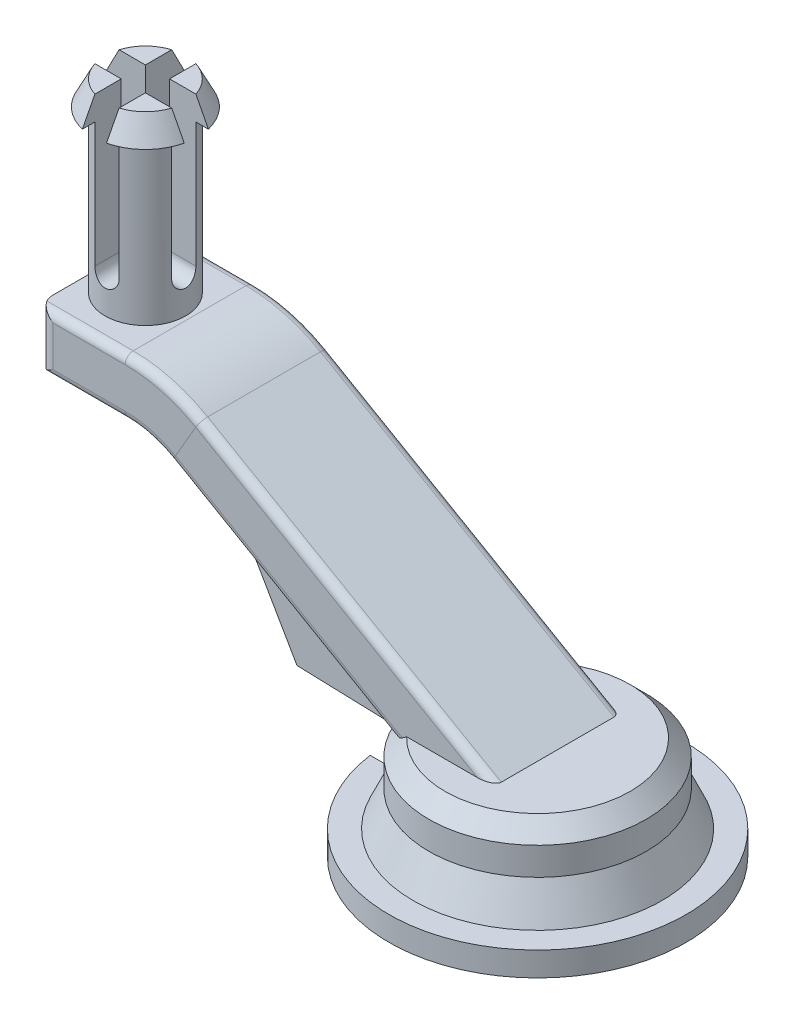
from build123d import *

# Parameters (mm, degrees)
CORTAR_EXTRUIR2_DEPTH         = 4.5
SALIENTE_EXTRUIR2_START       = -4.5
CROQUIS5_W                    = 16
CROQUIS5_H                    = 1.6
SALIENTE_EXTRUIR2_DEPTH       = 4.5
CROQUIS6_R                    = 2
SALIENTE_EXTRUIR3_DEPTH       = 4.4
SALIENTE_EXTRUIR10_DEPTH      = 4
SALIENTE_EXTRUIR10_DEPTH_BACK = 4
SALIENTE_EXTRUIR14_DEPTH      = 2
SALIENTE_EXTRUIR15_DEPTH      = 8
CORTAR_EXTRUIR3_DEPTH         = 2.5
CORTAR_EXTRUIR3_DEPTH_BACK    = 2.5
CROQUIS16_R                   = 2.5
CORTAR_EXTRUIR4_DEPTH         = 5
SALIENTE_EXTRUIR16_REACH      = 28.151
CROQUIS20_R                   = 5
SALIENTE_EXTRUIR17_DEPTH      = 20
CORTAR_EXTRUIR5_DEPTH         = 20
CORTAR_EXTRUIR6_DEPTH         = 20
CORTAR_EXTRUIR6_DEPTH_BACK    = 20
CORTAR_EXTRUIR7_DEPTH         = 16
CORTAR_EXTRUIR8_DEPTH         = 16
CROQUIS28_W                   = 13.74427346
CROQUIS28_H                   = 0.2
CORTAR_EXTRUIR9_DEPTH         = 1.6
SALIENTE_EXTRUIR18_DEPTH      = 2
SALIENTE_EXTRUIR19_DEPTH      = 2
CROQUIS31_R                   = 18.46058459
CORTAR_EXTRUIR10_DEPTH        = 10
CORTAR_EXTRUIR11_DEPTH        = 2
CORTAR_EXTRUIR11_DEPTH_BACK   = 1
CROQUIS33_R                   = 2.5
CORTAR_EXTRUIR12_DEPTH        = 6


with BuildPart() as part:
    # Croquis1 → Revoluci_n1 (revolve)
    with BuildSketch(Plane(origin=(53.410009494, 0, 0), x_dir=(0, 0, -1), z_dir=(1, 0, 0)), mode=Mode.PRIVATE) as revoluci_n1_sk:
        Polygon((0.52, 82.76), (10.040007849, 82.76), (11.02, 79.330027472), (11.02, 76.76), (14.02, 76.76), (14.02, 83.76), (12.02, 85.76), (0.52, 85.76), align=None)
    revolve(revoluci_n1_sk.sketch.rotate(Axis((53.410009494, 92.179923536, -0.52), (0, -1, 0)), 180), axis=Axis((53.410009494, 92.179923536, -0.52), (0, -1, 0)))  # turned: the seam where the file's is

    # Croquis4 → Cortar-Extruir2 (cut)
    with BuildSketch(Plane(origin=(0, 0, -2.77), x_dir=(-1, 0, 0), z_dir=(0, 0, -1))):
        Polygon((-49.430009494, 82.38), (-49.430009494, 81.16), (-58.115009494, 81.16), (-58.592032087, 81.16), (-58.592032087, 78.172909834), (-58.592032087, 74.185148135), (-34.769920464, 74.185148135), (-32.906639714, 80.223629187), (-43.587142857, 79.88), (-43.846492711, 79.88), (-44.767521138, 79.88), (-48.930009494, 79.88), (-48.930009494, 82.38), align=None)
        Polygon((-44.520009494, 82.38), (-48.930009494, 82.38), (-48.930009494, 79.88), (-44.767521138, 79.88), (-43.846492711, 79.88), (-43.587142857, 79.88), (-32.906639714, 80.223629187), (-32.526215481, 81.456500035), (-44.020009494, 81.086704433), (-44.520009494, 81.070617682), align=None)
        Polygon((-44.020009494, 82.38), (-44.520009494, 82.38), (-44.520009494, 81.070617682), (-44.020009494, 81.086704433), align=None)
        Polygon((-32.526215481, 81.456500035), (-32.906639714, 80.223629187), (-30.843736719, 80.29), align=None)
    extrude(amount=-CORTAR_EXTRUIR2_DEPTH, mode=Mode.SUBTRACT)

    # Croquis5 → Saliente-Extruir2 (add)
    with BuildSketch(Plane.XY.offset(1.73).offset(SALIENTE_EXTRUIR2_START)):
        with Locations((57.430009494, 81.96)):
            Rectangle(CROQUIS5_W, CROQUIS5_H)
    extrude(amount=SALIENTE_EXTRUIR2_DEPTH)

    # Croquis6 → Saliente-Extruir3 (add)
    with BuildSketch(Plane.XZ.offset(-81.16)):
        with Locations(Location((58.315009494, -0.52, 0), (0, 0, 90))):  # turned: the seam where the file's is
            Circle(CROQUIS6_R)
    extrude(amount=SALIENTE_EXTRUIR3_DEPTH)



with BuildPart() as body_2:
    # Croquis12 → Saliente-Extruir10 (new body, two sides)
    with BuildSketch(Plane.XY.offset(-0.52)) as saliente_extruir10_sk:
        Polygon((41.910009494, 85.76), (17.615780859, 99.786279442), (30.910009494, 76.76), (39.910009494, 76.76), (39.910009494, 83.76), align=None)
    extrude(amount=SALIENTE_EXTRUIR10_DEPTH)
    extrude(saliente_extruir10_sk.sketch, amount=-SALIENTE_EXTRUIR10_DEPTH_BACK)

    # Croquis13 → Saliente-Extruir14 (add)
    with BuildSketch(Plane(origin=(0, 85.76, 0), x_dir=(1, 0, 0), z_dir=(0, 1, 0))):
        with BuildLine():
            Line((41.910009494, -3.48), (40.516212535, -3.48))
            ThreePointArc((40.516212535, -3.48), (39.910009494, 0.52), (40.516212535, 4.52))
            Line((40.516212535, 4.52), (41.910009494, 4.52))
            Line((41.910009494, 4.52), (42.628080167, 4.52))
            ThreePointArc((42.628080167, 4.52), (41.910009494, 0.52), (42.628080167, -3.48))
            Line((42.628080167, -3.48), (41.910009494, -3.48))
        make_face()
    extrude(amount=-SALIENTE_EXTRUIR14_DEPTH)


with BuildPart() as part_1:
    add(part.part)

    add(body_2.part)  # Saliente-Extruir15 merges body 2
    # Croquis14 → Saliente-Extruir15 (add)
    with BuildSketch(Plane.XZ.offset(-76.76)):
        with BuildLine():
            Line((39.910009494, -4.52), (39.910009494, -0.52))
            ThreePointArc((39.910009494, -0.52), (40.062420593, -2.542837248), (40.516212535, -4.52))
            Line((40.516212535, -4.52), (39.910009494, -4.52))
        make_face()
    saliente_extruir15 = extrude(amount=-SALIENTE_EXTRUIR15_DEPTH)

    # Simetr_a1: Saliente-Extruir15 across plane
    add(saliente_extruir15.mirror(Plane.XY.offset(-0.52)))

    # Croquis15 → Cortar-Extruir3 (cut, two sides)
    with BuildSketch(Plane.XY.offset(-0.52)) as cortar_extruir3_sk:
        Polygon((40.098829982, 81.212862509), (27.577127223, 81.611673338), (27.577127223, 75.881624113), (40.098829982, 75.881624113), align=None)
    extrude(amount=CORTAR_EXTRUIR3_DEPTH, mode=Mode.SUBTRACT)
    extrude(cortar_extruir3_sk.sketch, amount=-CORTAR_EXTRUIR3_DEPTH_BACK, mode=Mode.SUBTRACT)

    # Croquis16 → Cortar-Extruir4 (cut)
    with BuildSketch(Plane(origin=(2.624608287, 82.406400298, 0), x_dir=(0.999493188, -0.031833427, 0), z_dir=(-0.031833427, -0.999493188, 0))):
        with Locations((32.197981897, -0.52)):
            Circle(CROQUIS16_R)
    extrude(amount=-CORTAR_EXTRUIR4_DEPTH, mode=Mode.SUBTRACT)

    # Croquis17 → Saliente-Extruir16 (add, up to next)
    with BuildSketch(Plane(origin=(-5.702662194, 3.292433553, 0), x_dir=(0, 0, 1), z_dir=(-0.866025404, 0.5, 0)), mode=Mode.PRIVATE) as saliente_extruir16_sk1:
        with BuildLine():
            Line((6.48, 102.225343375), (-7.52, 102.225343375))
            ThreePointArc((-7.52, 102.225343375), (-8.227106781, 101.932450157), (-8.52, 101.225343375))
            Line((-8.52, 101.225343375), (-8.52, 96.225343375))
            ThreePointArc((-8.52, 96.225343375), (-8.227106781, 95.518236594), (-7.52, 95.225343375))
            Line((-7.52, 95.225343375), (6.48, 95.225343375))
            ThreePointArc((6.48, 95.225343375), (7.187106781, 95.518236594), (7.48, 96.225343375))
            Line((7.48, 96.225343375), (7.48, 101.225343375))
            ThreePointArc((7.48, 101.225343375), (7.187106781, 101.932450157), (6.48, 102.225343375))
        make_face()
    saliente_extruir16_tool1 = extrude(saliente_extruir16_sk1.sketch, amount=-SALIENTE_EXTRUIR16_REACH, mode=Mode.PRIVATE) - part_1.part
    add(saliente_extruir16_tool1.solids().sort_by_distance((43.660009, 88.791089, -0.52))[0])

    # Barrer1: sweep along a path in Croquis18
    with BuildLine(Plane.XY.offset(-0.52)) as barrer1_path:
        Line((43.660009494, 88.791088913), (17.695907878, 103.78146997))
        ThreePointArc((17.695907878, 103.78146997), (14.078193555, 105.279976308), (10.195907878, 105.791088913))
        Line((10.195907878, 105.791088913), (-0.784854235, 105.791088913))
    # Croquis19 → Barrer1 (sweep)
    with BuildSketch(Plane(origin=(-5.702662194, 3.292433553, 0), x_dir=(0, 0, 1), z_dir=(-0.866025404, 0.5, 0))):
        with BuildLine():
            Line((-7.52, 95.225343375), (-4.52, 95.225343375))
            Line((-4.52, 95.225343375), (3.48, 95.225343375))
            Line((3.48, 95.225343375), (6.48, 95.225343375))
            ThreePointArc((6.48, 95.225343375), (7.187106781, 95.518236594), (7.48, 96.225343375))
            Line((7.48, 96.225343375), (7.48, 101.225343375))
            ThreePointArc((7.48, 101.225343375), (7.187106781, 101.932450157), (6.48, 102.225343375))
            Line((6.48, 102.225343375), (-7.52, 102.225343375))
            ThreePointArc((-7.52, 102.225343375), (-8.227106781, 101.932450157), (-8.52, 101.225343375))
            Line((-8.52, 101.225343375), (-8.52, 96.225343375))
            ThreePointArc((-8.52, 96.225343375), (-8.227106781, 95.518236594), (-7.52, 95.225343375))
        make_face()
    sweep(path=barrer1_path.line)

    # Croquis20 → Saliente-Extruir17 (add)
    with BuildSketch(Plane(origin=(0, 109.291088913, 0), x_dir=(1, 0, 0), z_dir=(0, 1, 0))):
        with Locations(Location((4.705526822, 0.52, 0), (0, 0, 270))):  # turned: the seam where the file's is
            Circle(CROQUIS20_R)
    extrude(amount=SALIENTE_EXTRUIR17_DEPTH)

    # Croquis21 → Revoluci_n2 (revolve)
    with BuildSketch(Plane.XY.offset(-0.52), mode=Mode.PRIVATE) as revoluci_n2_sk:
        Polygon((4.705526822, 129.291088913), (11.205526822, 129.291088913), (9.705526822, 132.291088913), (4.705526822, 132.291088913), align=None)
    revolve(revoluci_n2_sk.sketch.rotate(Axis((4.705526822, 132.291088913, -0.52), (0, -1, 0)), 90), axis=Axis((4.705526822, 132.291088913, -0.52), (0, -1, 0)))  # turned: the seam where the file's is

    # Croquis22 → Cortar-Extruir5 (cut)
    with BuildSketch(Plane.XY.offset(7.48)):
        with BuildLine():
            Line((6.205526822, 132.291088913), (3.205526822, 132.291088913))
            Line((3.205526822, 132.291088913), (3.205526822, 113.791088913))
            ThreePointArc((3.205526822, 113.791088913), (4.705526822, 112.291088913), (6.205526822, 113.791088913))
            Line((6.205526822, 113.791088913), (6.205526822, 132.291088913))
        make_face()
    extrude(amount=-CORTAR_EXTRUIR5_DEPTH, mode=Mode.SUBTRACT)

    # Croquis23 → Cortar-Extruir6 (cut, two sides)
    with BuildSketch(Plane.ZY.offset(0.784854235)) as cortar_extruir6_sk:
        with BuildLine():
            Line((0.98, 132.291088913), (-2.02, 132.291088913))
            Line((-2.02, 132.291088913), (-2.02, 113.791088913))
            ThreePointArc((-2.02, 113.791088913), (-0.52, 112.291088913), (0.98, 113.791088913))
            Line((0.98, 113.791088913), (0.98, 132.291088913))
        make_face()
    extrude(amount=CORTAR_EXTRUIR6_DEPTH, mode=Mode.SUBTRACT)
    extrude(cortar_extruir6_sk.sketch, amount=-CORTAR_EXTRUIR6_DEPTH_BACK, mode=Mode.SUBTRACT)

    # Croquis24 → Cortar-Extruir7 (cut)
    with BuildSketch(Plane.XZ.offset(-102.291088913)):
        with BuildLine():
            Line((10.195907878, 7.48), (1.215145765, 7.48))
            ThreePointArc((1.215145765, 7.48), (-0.199067798, 6.894213562), (-0.784854235, 5.48))
            Line((-0.784854235, 5.48), (-0.784854235, -6.52))
            ThreePointArc((-0.784854235, -6.52), (-0.199067798, -7.934213562), (1.215145765, -8.52))
            Line((1.215145765, -8.52), (10.195907878, -8.52))
            Line((10.195907878, -8.52), (-7.358122768, -12.733929772))
            Line((-7.358122768, -12.733929772), (-8.018635772, 9.663465708))
            Line((-8.018635772, 9.663465708), (10.195907878, 7.48))
        make_face()
    extrude(amount=-CORTAR_EXTRUIR7_DEPTH, mode=Mode.SUBTRACT)

    # Croquis25 → Revoluci_n3 (revolve)
    with BuildSketch(Plane.XY.offset(-0.52), mode=Mode.PRIVATE) as revoluci_n3_sk:
        Polygon((65.229279398, 76.76), (66.939279398, 73), (73.870594084, 73), (73.870594084, 76), (68.870594084, 76), (66.910009494, 80.310993017), (66.910009494, 76.76), align=None)
    revolve(revoluci_n3_sk.sketch.rotate(Axis((53.410009494, 92.179923536, -0.52), (0, -1, 0)), 197.235282756), axis=Axis((53.410009494, 92.179923536, -0.52), (0, -1, 0)))  # turned: the seam where the file's is

    # Croquis26 → Cortar-Extruir8 (cut)
    with BuildSketch(Plane(origin=(2.624608287, 82.406400298, 0), x_dir=(0.999493188, -0.031833427, 0), z_dir=(-0.031833427, -0.999493188, 0))):
        with BuildLine():
            Line((37.493223709, -3.02), (41.133994851, -3.02))
            ThreePointArc((41.133994851, -3.02), (40.819210883, -0.52), (41.133994851, 1.98))
            Line((41.133994851, 1.98), (37.493223709, 1.98))
            Line((37.493223709, 1.98), (32.197981897, 1.98))
            Line((32.197981897, 1.98), (22.206808527, 1.98))
            Line((22.206808527, 1.98), (22.206808527, -3.02))
            Line((22.206808527, -3.02), (32.197981897, -3.02))
            Line((32.197981897, -3.02), (37.493223709, -3.02))
        make_face()
    extrude(amount=CORTAR_EXTRUIR8_DEPTH, mode=Mode.SUBTRACT)

    # Croquis27 → Cortar-Revoluci_n1 (revolve, cut)
    with BuildSketch(Plane.XY.offset(-0.52), mode=Mode.PRIVATE) as cortar_revoluci_n1_sk:
        Polygon((68.870594084, 76), (96.211885499, 76), (96.211885499, 80), (67.051445148, 80), align=None)
    revolve(cortar_revoluci_n1_sk.sketch.rotate(Axis((53.410009494, 92.179923536, -0.52), (0, -1, 0)), 194.484742099), axis=Axis((53.410009494, 92.179923536, -0.52), (0, -1, 0)), mode=Mode.SUBTRACT)  # turned: the seam where the file's is

    # Croquis28 → Cortar-Extruir9 (cut)
    with BuildSketch(Plane.XZ.offset(-81.16)):
        with Locations((56.302146224, 1.63)):
            Rectangle(CROQUIS28_W, CROQUIS28_H)
        with Locations((56.302146224, -2.67)):
            Rectangle(CROQUIS28_W, CROQUIS28_H)
    extrude(amount=-CORTAR_EXTRUIR9_DEPTH, mode=Mode.SUBTRACT)

    # Croquis29 → Saliente-Extruir18 (add)
    with BuildSketch(Plane(origin=(0, 0, 1.73), x_dir=(-1, 0, 0), z_dir=(0, 0, -1))):
        with BuildLine():
            Line((-62.660309459, 82.76), (-63.174282954, 82.76))
            Line((-63.174282954, 82.76), (-63.174282954, 81.16))
            Line((-63.174282954, 81.16), (-63.1301451, 81.16))
            ThreePointArc((-63.1301451, 81.16), (-62.895370026, 81.960041917), (-62.660309459, 82.76))
        make_face()
    extrude(amount=SALIENTE_EXTRUIR18_DEPTH)

    # Croquis30 → Saliente-Extruir19 (add)
    with BuildSketch(Plane.XY.offset(-2.77)):
        with BuildLine():
            Line((63.1301451, 81.16), (63.174282954, 81.16))
            Line((63.174282954, 81.16), (63.174282954, 82.76))
            Line((63.174282954, 82.76), (62.660309459, 82.76))
            ThreePointArc((62.660309459, 82.76), (62.895370026, 81.960041917), (63.1301451, 81.16))
        make_face()
    extrude(amount=SALIENTE_EXTRUIR19_DEPTH)

    # Croquis31 → Cortar-Extruir10 (cut)
    with BuildSketch(Plane(origin=(0, 76, 0), x_dir=(1, 0, 0), z_dir=(0, 1, 0))):
        with BuildLine():
            Line((33.102731937, 3.02), (33.102731937, -1.98))
            ThreePointArc((33.102731937, -1.98), (73.870594084, 0.52), (33.102731937, 3.02))
        make_face()
        with Locations((53.410009494, 0.52)):
            Circle(CROQUIS31_R, mode=Mode.SUBTRACT)
    extrude(amount=-CORTAR_EXTRUIR10_DEPTH, mode=Mode.SUBTRACT)

    # Croquis32 → Cortar-Extruir11 (cut, two sides)
    with BuildSketch(Plane(origin=(2.624608287, 82.406400298, 0), x_dir=(0.999493188, -0.031833427, 0), z_dir=(-0.031833427, -0.999493188, 0))) as cortar_extruir11_sk:
        with BuildLine():
            Line((37.801067856, -4.52), (26.478002973, -4.52))
            Line((26.478002973, -4.52), (19.955118683, -4.52))
            Line((19.955118683, -4.52), (19.955118683, 3.48))
            Line((19.955118683, 3.48), (26.478002973, 3.48))
            Line((26.478002973, 3.48), (37.801067856, 3.48))
            add(Edge.make_bspline(
                [(37.801067856, 3.48), (37.574358632, 2.740450621), (37.432665367, 1.98)],
                knots=[1.273198713, 1.273198713, 1.273198713, 1.386489476, 1.386489476, 1.386489476], degree=2, weights=[1, 0.998396079, 1]))
            Line((37.432665367, 1.98), (41.12883378, 1.98))
            add(Edge.make_bspline(
                [(41.12883378, 1.98), (40.488688951, -0.52), (41.12883378, -3.02)],
                knots=[2.891052322, 2.891052322, 2.891052322, 3.392132985, 3.392132985, 3.392132985], degree=2, weights=[1, 0.9687786, 1]))
            Line((41.12883378, -3.02), (37.432665367, -3.02))
            add(Edge.make_bspline(
                [(37.432665367, -3.02), (37.574358632, -3.780450621), (37.801067856, -4.52)],
                knots=[1.755103178, 1.755103178, 1.755103178, 1.868393941, 1.868393941, 1.868393941], degree=2, weights=[1, 0.998396079, 1]))
        make_face()
    extrude(amount=CORTAR_EXTRUIR11_DEPTH, mode=Mode.SUBTRACT)
    extrude(cortar_extruir11_sk.sketch, amount=-CORTAR_EXTRUIR11_DEPTH_BACK, mode=Mode.SUBTRACT)

    # Croquis33 → Cortar-Extruir12 (cut)
    with BuildSketch(Plane(origin=(2.656441713, 83.405893486, 0), x_dir=(0.999493188, -0.031833427, 0), z_dir=(-0.031833427, -0.999493188, 0))):
        with Locations((32.197981897, -0.52)):
            Circle(CROQUIS33_R)
    extrude(amount=-CORTAR_EXTRUIR12_DEPTH, mode=Mode.SUBTRACT)


solid = part_1.part
